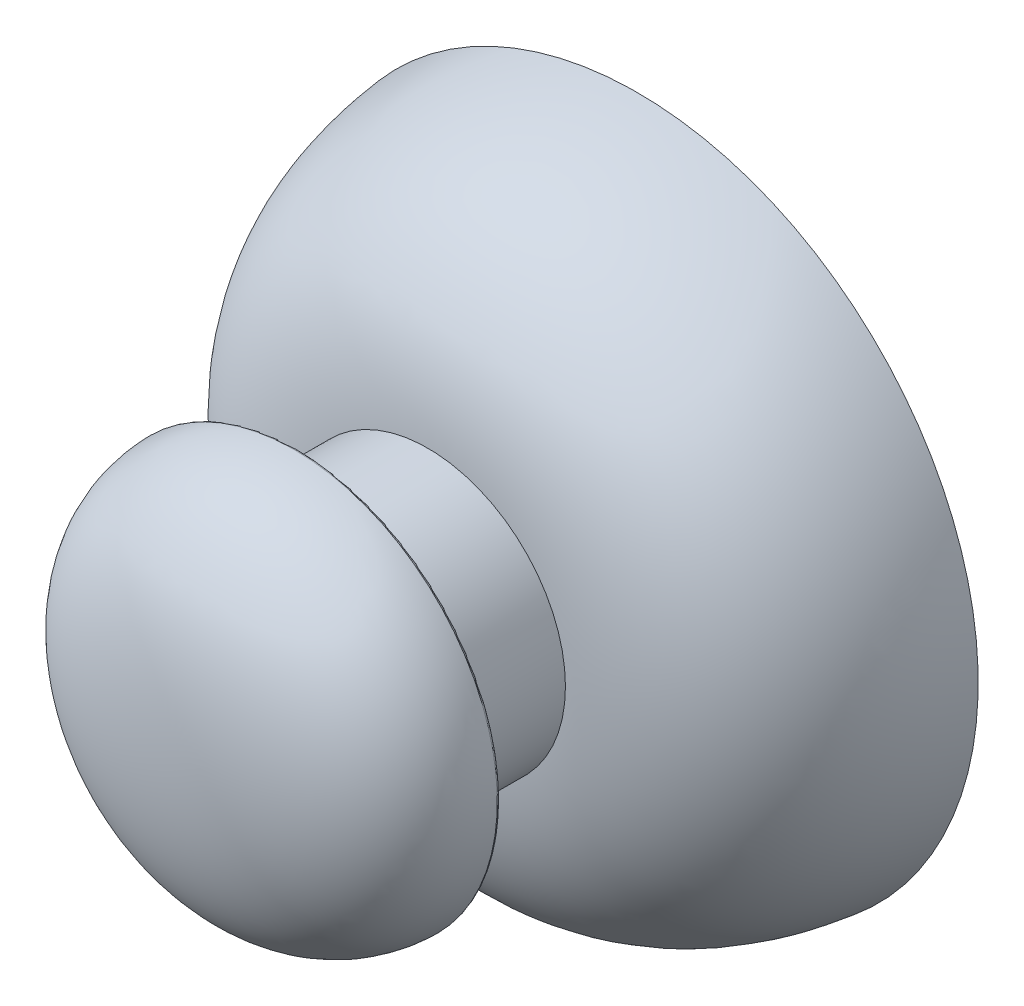
from build123d import *

# Parameters (mm, degrees)
SKETCH_2_R      = 5.25
EXTRUDE_1_DEPTH = 8
SKETCH_4_R      = 5.25
EXTRUDE_2_DEPTH = 5
FILLET_1_R      = 0.1


with BuildPart() as part:
    # 草图2 → 凸台-拉伸1 (new body)
    with BuildSketch(Plane.XY):
        Circle(SKETCH_2_R)
    extrude(amount=EXTRUDE_1_DEPTH)

    # 草图3 → 旋转1 (revolve)
    with BuildSketch(Plane(origin=(0, 0, 0), x_dir=(0, 0, -1), z_dir=(1, 0, 0))):
        with BuildLine():
            Line((-8, 0), (-8, -5.25))
            add(Edge.make_bspline(
                [(0, -13), (-5.068934353, -12.456863927), (-7.746723487, -9.679032619), (-8, -5.25)],
                knots=[0, 0, 0, 0, 1, 1, 1, 1], degree=3))
            Line((0, -13), (0, 0))
            Line((0, 0), (-8, 0))
        make_face()
    revolve(axis=Axis((0, 0, 0), (0, 0, 1)))

    # 草图4 → 凸台-拉伸2 (add)
    with BuildSketch(Plane.XY.offset(8)):
        Circle(SKETCH_4_R)
    extrude(amount=EXTRUDE_2_DEPTH)

    # 草图6 → 旋转2 (revolve)
    with BuildSketch(Plane(origin=(0, 0, 0), x_dir=(0, 0, -1), z_dir=(1, 0, 0))):
        with BuildLine():
            Line((-13, 0), (-18, 0))
            add(Edge.make_bspline(
                [(-18, 0), (-18, 7.56404748), (-13.939261077, 7.75465321), (-13, 7.75465321)],
                knots=[0, 0, 0, 0, 1, 1, 1, 1], degree=3))
            Line((-13, 7.75465321), (-13, 0))
        make_face()
    revolve(axis=Axis((0, 0, 13), (0, 0, 1)))

    # 圆角1
    fillet_1_edges = [part.edges().sort_by_distance(p)[0] for p in [
        (-5.25, 0, 13),
        (0, -7.75465321, 13),
    ]]
    fillet(fillet_1_edges, radius=FILLET_1_R)


solid = part.part
